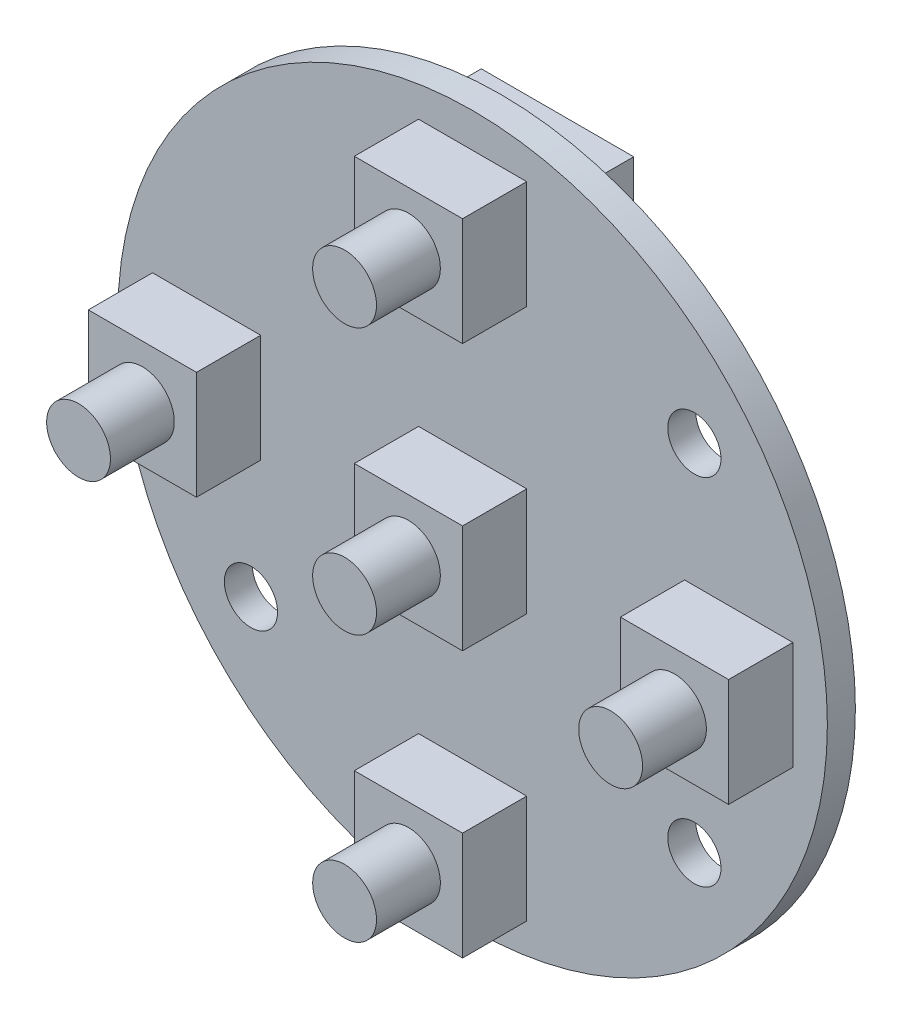
from build123d import *

# Parameters (mm, degrees)
ESQUISSE3_R        = 20
ESQUISSE3_R_2      = 1.5
ESQUISSE3_W        = 6.1
ESQUISSE3_H        = 6.1
BOSS_EXTRU_2_DEPTH = 1.58
ESQUISSE5_W        = 6.1
ESQUISSE5_H        = 6.1
BOSS_EXTRU_3_DEPTH = 5.2
ESQUISSE6_R        = 1.8
BOSS_EXTRU_4_DEPTH = 3.6
ESQUISSE7_W        = 8.59
ESQUISSE7_H        = 20.3
BOSS_EXTRU_5_DEPTH = 9.92


with BuildPart() as part:
    # Esquisse3 → Boss.-Extru.2 (new body)
    with BuildSketch(Plane.XY):
        Circle(ESQUISSE3_R)
        with Locations((-12.5, -10)):
            Circle(ESQUISSE3_R_2, mode=Mode.SUBTRACT)
        with Locations((12.5, -10)):
            Circle(ESQUISSE3_R_2, mode=Mode.SUBTRACT)
        with Locations((12.5, 10)):
            Circle(ESQUISSE3_R_2, mode=Mode.SUBTRACT)
        with Locations((-15, 0)):
            Rectangle(ESQUISSE3_W, ESQUISSE3_H, mode=Mode.SUBTRACT)
        with Locations((15, 0)):
            Rectangle(ESQUISSE3_W, ESQUISSE3_H, mode=Mode.SUBTRACT)
        with Locations((0, 15)):
            Rectangle(ESQUISSE3_W, ESQUISSE3_H, mode=Mode.SUBTRACT)
        with Locations((0, -15)):
            Rectangle(ESQUISSE3_W, ESQUISSE3_H, mode=Mode.SUBTRACT)
        Rectangle(ESQUISSE3_W, ESQUISSE3_H, mode=Mode.SUBTRACT)
    extrude(amount=BOSS_EXTRU_2_DEPTH)

    # Esquisse5 → Boss.-Extru.3 (add)
    with BuildSketch(Plane(origin=(0, 0, 0), x_dir=(-1, 0, 0), z_dir=(0, 0, -1))):
        with Locations((0, 15)):
            Rectangle(ESQUISSE5_W, ESQUISSE5_H)
        with Locations((-15, 0)):
            Rectangle(ESQUISSE5_W, ESQUISSE5_H)
        with Locations((15, 0)):
            Rectangle(ESQUISSE5_W, ESQUISSE5_H)
        Rectangle(ESQUISSE5_W, ESQUISSE5_H)
        with Locations((0, -15)):
            Rectangle(ESQUISSE5_W, ESQUISSE5_H)
    extrude(amount=-BOSS_EXTRU_3_DEPTH)

    # Esquisse6 → Boss.-Extru.4 (add)
    with BuildSketch(Plane.XY.offset(5.2)):
        Circle(ESQUISSE6_R)
        with Locations((0, 15)):
            Circle(ESQUISSE6_R)
        with Locations((15, 0)):
            Circle(ESQUISSE6_R)
        with Locations((0, -15)):
            Circle(ESQUISSE6_R)
        with Locations((-15, 0)):
            Circle(ESQUISSE6_R)
    extrude(amount=BOSS_EXTRU_4_DEPTH)

    # Esquisse7 → Boss.-Extru.5 (add)
    with BuildSketch(Plane.XY):
        with Locations((-6.715, 0.63)):
            Rectangle(ESQUISSE7_W, ESQUISSE7_H)
    extrude(amount=-BOSS_EXTRU_5_DEPTH)


solid = part.part
